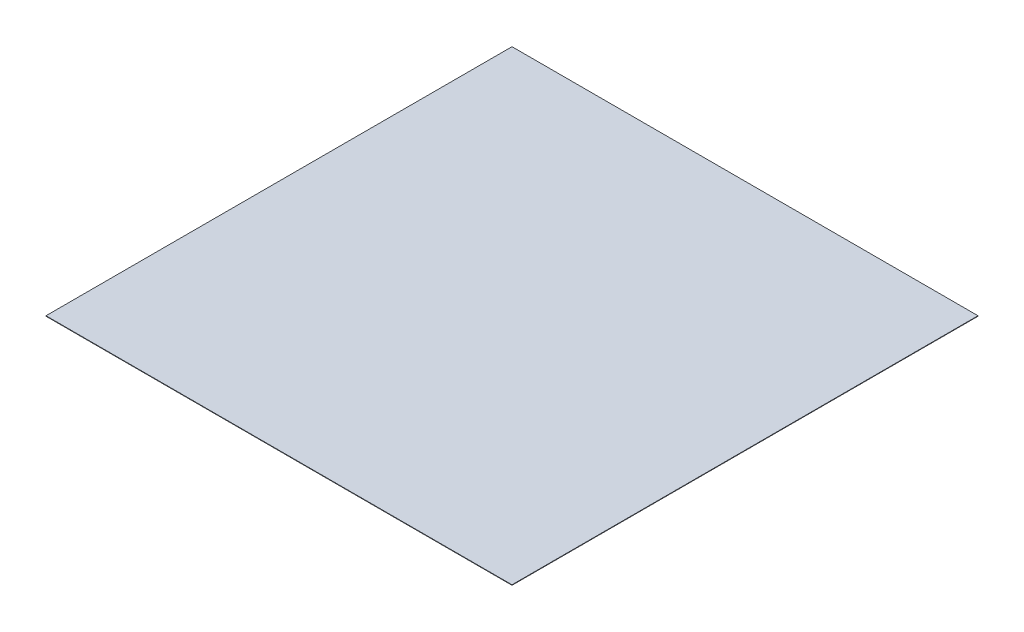
from build123d import *

# Parameters (mm, degrees)
SKETCH_1_W      = 1000
SKETCH_1_H      = 1000
EXTRUDE_1_DEPTH = 1


with BuildPart() as part:
    # 草图1 → 凸台-拉伸1 (new body)
    with BuildSketch(Plane(origin=(0, 0, 0), x_dir=(1, 0, 0), z_dir=(0, 1, 0))):
        Rectangle(SKETCH_1_W, SKETCH_1_H)
    extrude(amount=EXTRUDE_1_DEPTH)


solid = part.part
